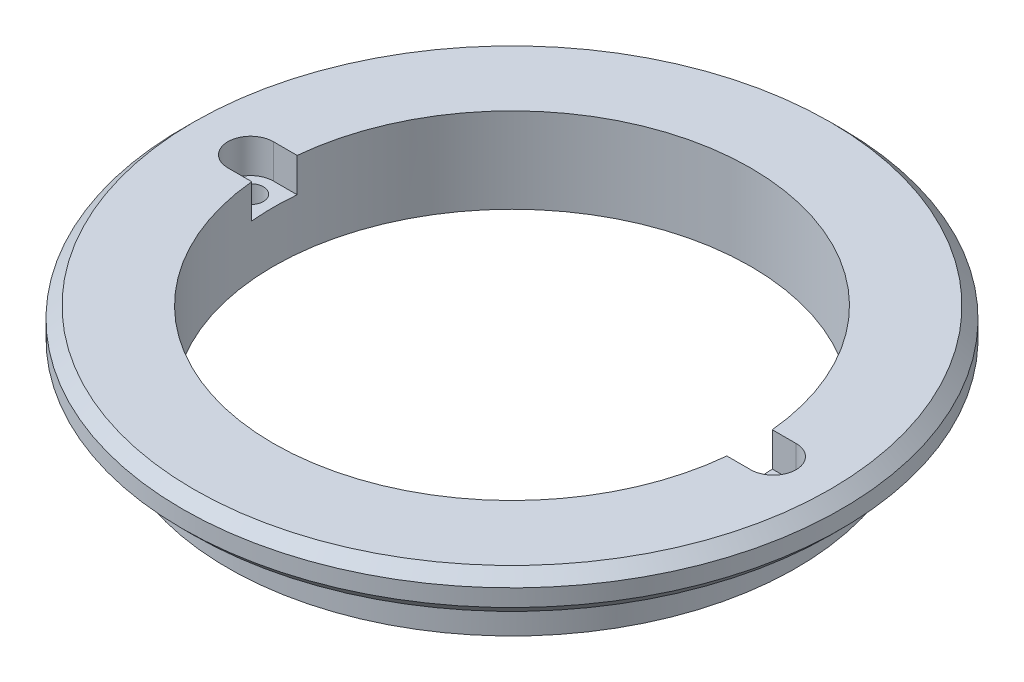
from build123d import *

# Parameters (mm, degrees)
SKETCH2_R          = 1.125
CUT_EXTRUDE1_DEPTH = 8.5
CUT_EXTRUDE3_DEPTH = 3


with BuildPart() as part:
    # Sketch1 → Revolve1 (revolve)
    with BuildSketch(Plane.XY):
        Polygon((-29, 5), (-29, 6.5), (-28, 7.5), (-21, 7.5), (-21, 0), (-25, 0), (-25, 4), (-28, 4), align=None)
    revolve(axis=Axis((0, 0, 0), (0, 1, 0)))

    # Sketch2 → Cut-Extrude1 (cut, through all)
    with BuildSketch(Plane.XZ):
        with Locations((-23, 0)):
            Circle(SKETCH2_R)
        with Locations((23, 0)):
            Circle(SKETCH2_R)
    extrude(amount=-CUT_EXTRUDE1_DEPTH, mode=Mode.SUBTRACT)

    # Sketch3 → Cut-Extrude3 (cut)
    with BuildSketch(Plane(origin=(0, 7.5, 0), x_dir=(1, 0, 0), z_dir=(0, 1, 0))):
        with BuildLine():
            Line((-23, 2), (23, 2))
            ThreePointArc((23, 2), (25, 0), (23, -2))
            Line((23, -2), (-23, -2))
            ThreePointArc((-23, -2), (-25, 0), (-23, 2))
        make_face()
    extrude(amount=-CUT_EXTRUDE3_DEPTH, mode=Mode.SUBTRACT)


solid = part.part
